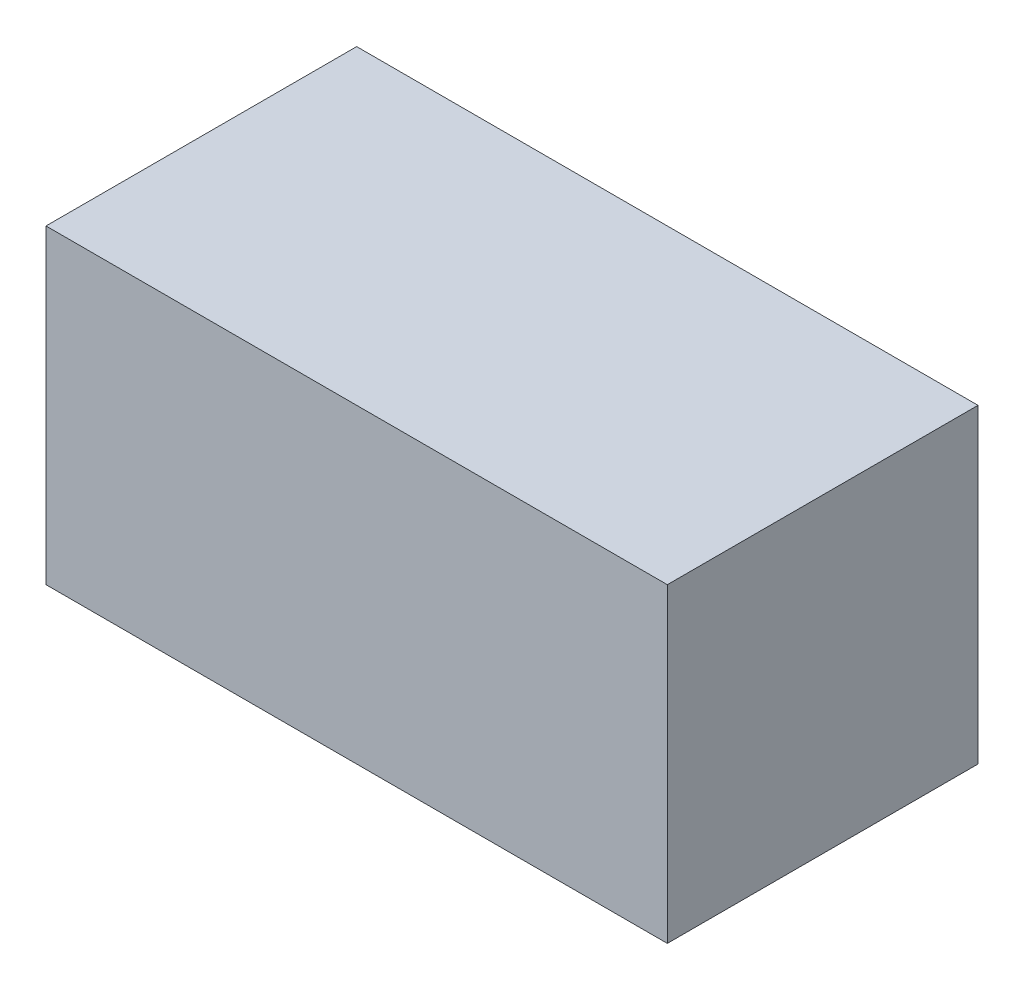
from build123d import *

# Parameters (mm, degrees)
SKETCH1_W      = 20
SKETCH1_H      = 10
EXTRUDE1_DEPTH = 10


with BuildPart() as part:
    # Sketch1 → Extrude1 (new body)
    with BuildSketch(Plane(origin=(0, 0, 0), x_dir=(1, 0, 0), z_dir=(0, 1, 0))):
        with Locations((10, 5)):
            Rectangle(SKETCH1_W, SKETCH1_H)
    extrude(amount=EXTRUDE1_DEPTH)


solid = part.part
